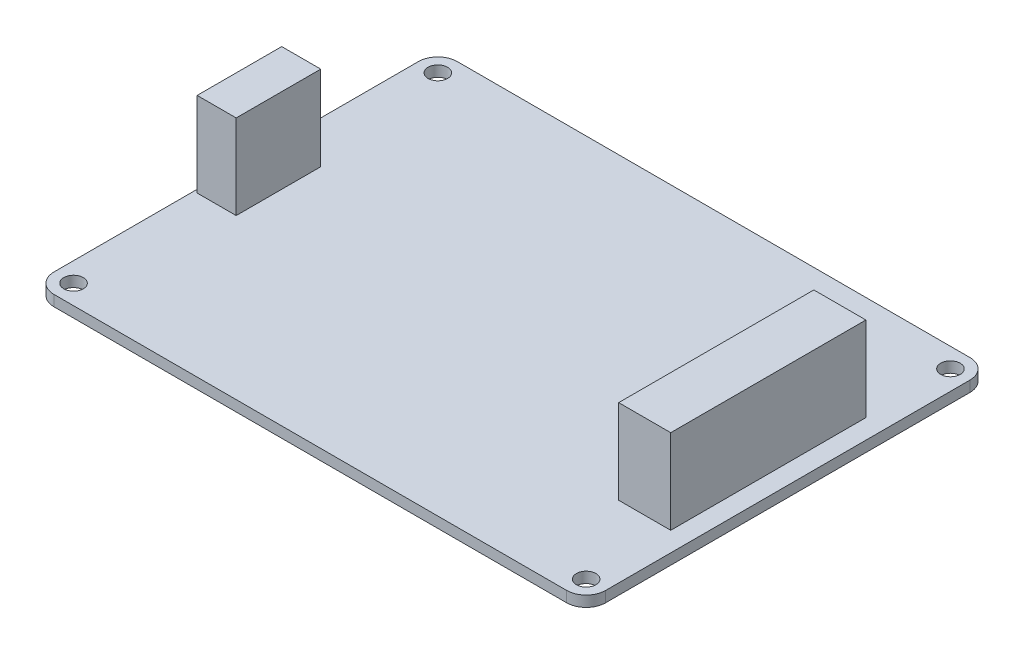
from build123d import *

# Parameters (mm, degrees)
SKETCH1_W           = 84.8
SKETCH1_H           = 62
SKETCH1_R           = 1.5
BOSS_EXTRUDE1_DEPTH = 1.65
FILLET1_R           = 3
SKETCH2_W           = 6
SKETCH2_H           = 13
SKETCH2_W_2         = 8
SKETCH2_H_2         = 30
BOSS_EXTRUDE2_DEPTH = 13


with BuildPart() as part:
    # Sketch1 → Boss-Extrude1 (new body)
    with BuildSketch(Plane(origin=(0, 0, 0), x_dir=(1, 0, 0), z_dir=(0, 1, 0))):
        Rectangle(SKETCH1_W, SKETCH1_H)
        with Locations((-39.4, 28)):
            Circle(SKETCH1_R, mode=Mode.SUBTRACT)
        with Locations((39.4, 28)):
            Circle(SKETCH1_R, mode=Mode.SUBTRACT)
        with Locations((39.4, -28)):
            Circle(SKETCH1_R, mode=Mode.SUBTRACT)
        with Locations((-39.4, -28)):
            Circle(SKETCH1_R, mode=Mode.SUBTRACT)
    extrude(amount=BOSS_EXTRUDE1_DEPTH)

    # Fillet1
    fillet1_edges = [part.edges().sort_by_distance(p)[0] for p in [
        (-42.4, 0.825, -31),
        (42.4, 0.825, -31),
        (42.4, 0.825, 31),
        (-42.4, 0.825, 31),
    ]]
    fillet(fillet1_edges, radius=FILLET1_R)

    # Sketch2 → Boss-Extrude2 (add)
    with BuildSketch(Plane(origin=(0, 1.65, 0), x_dir=(1, 0, 0), z_dir=(0, 1, 0))):
        with Locations((-38.9, 0)):
            Rectangle(SKETCH2_W, SKETCH2_H)
        with Locations((35.4, 0)):
            Rectangle(SKETCH2_W_2, SKETCH2_H_2)
    extrude(amount=BOSS_EXTRUDE2_DEPTH)


solid = part.part
